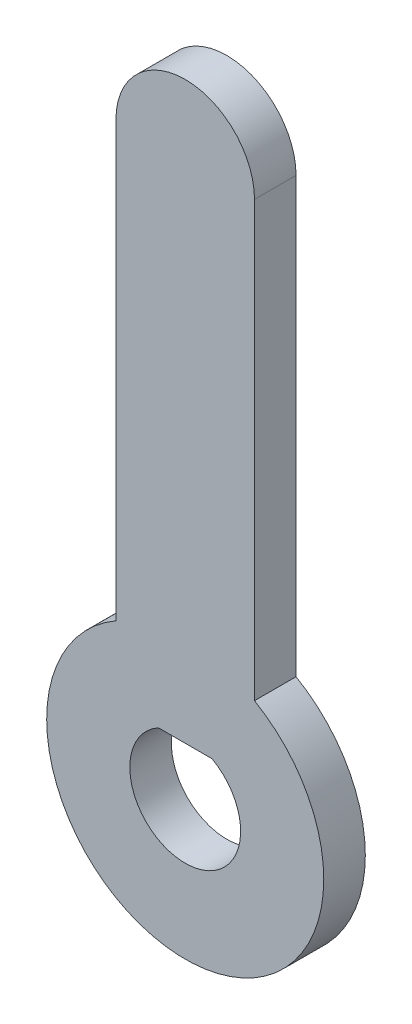
from build123d import *

# Parameters (mm, degrees)
EXTRUSION1_DEPTH = 3
EXTRUSION2_DEPTH = 4


with BuildPart() as part:
    # Esquisse1 → Extrusion1 (new body)
    with BuildSketch(Plane.XY):
        with BuildLine():
            Line((-5, 8.660254038), (-5, 40))
            ThreePointArc((-5, 40), (0, 45), (5, 40))
            Line((5, 40), (5, 8.660254038))
            ThreePointArc((5, 8.660254038), (0, -10), (-5, 8.660254038))
        make_face()
    extrude(amount=EXTRUSION1_DEPTH)

    # Esquisse2 → Extrusion2 (cut, through all)
    with BuildSketch(Plane.XY.offset(3)):
        with BuildLine():
            Line((-1.936491673, 3.5), (1.936491673, 3.5))
            ThreePointArc((1.936491673, 3.5), (0, -4), (-1.936491673, 3.5))
        make_face()
    extrude(amount=-EXTRUSION2_DEPTH, mode=Mode.SUBTRACT)


solid = part.part
